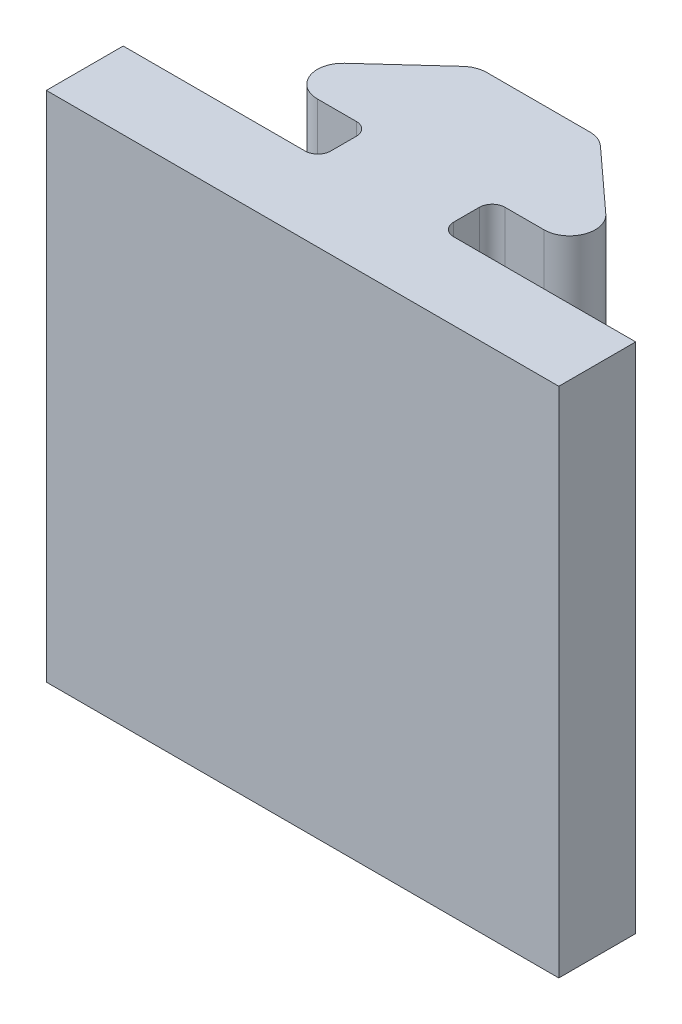
from build123d import *

# Parameters (mm, degrees)
BOSS_EXTRUDE1_DEPTH = 20
FILLET1_R           = 1
FILLET2_R           = 0.5


with BuildPart() as part:
    # Sketch1 → Boss-Extrude1 (new body)
    with BuildSketch(Plane(origin=(0, 0, 0), x_dir=(1, 0, 0), z_dir=(0, 1, 0))):
        Polygon((-2.4, 4.581818182), (2.4, 4.581818182), (7, 0.381818182), (2.4, 0.381818182), (2.4, -1.618181818), (10, -1.618181818), (10, -4.618181818), (-10, -4.618181818), (-10, -1.618181818), (-2.4, -1.618181818), (-2.4, 0.381818182), (-7, 0.381818182), align=None)
    extrude(amount=BOSS_EXTRUDE1_DEPTH)

    # Fillet1
    fillet1_edges = [part.edges().sort_by_distance(p)[0] for p in [
        (7, 10, -0.381818182),
        (-7, 10, -0.381818182),
        (-2.4, 10, -4.581818182),
        (2.4, 10, -4.581818182),
    ]]
    fillet(fillet1_edges, radius=FILLET1_R)

    # Fillet2
    fillet2_edges = [part.edges().sort_by_distance(p)[0] for p in [
        (2.4, 10, -0.381818182),
        (2.4, 10, 1.618181818),
        (-2.4, 10, 1.618181818),
        (-2.4, 10, -0.381818182),
    ]]
    fillet(fillet2_edges, radius=FILLET2_R)


solid = part.part
